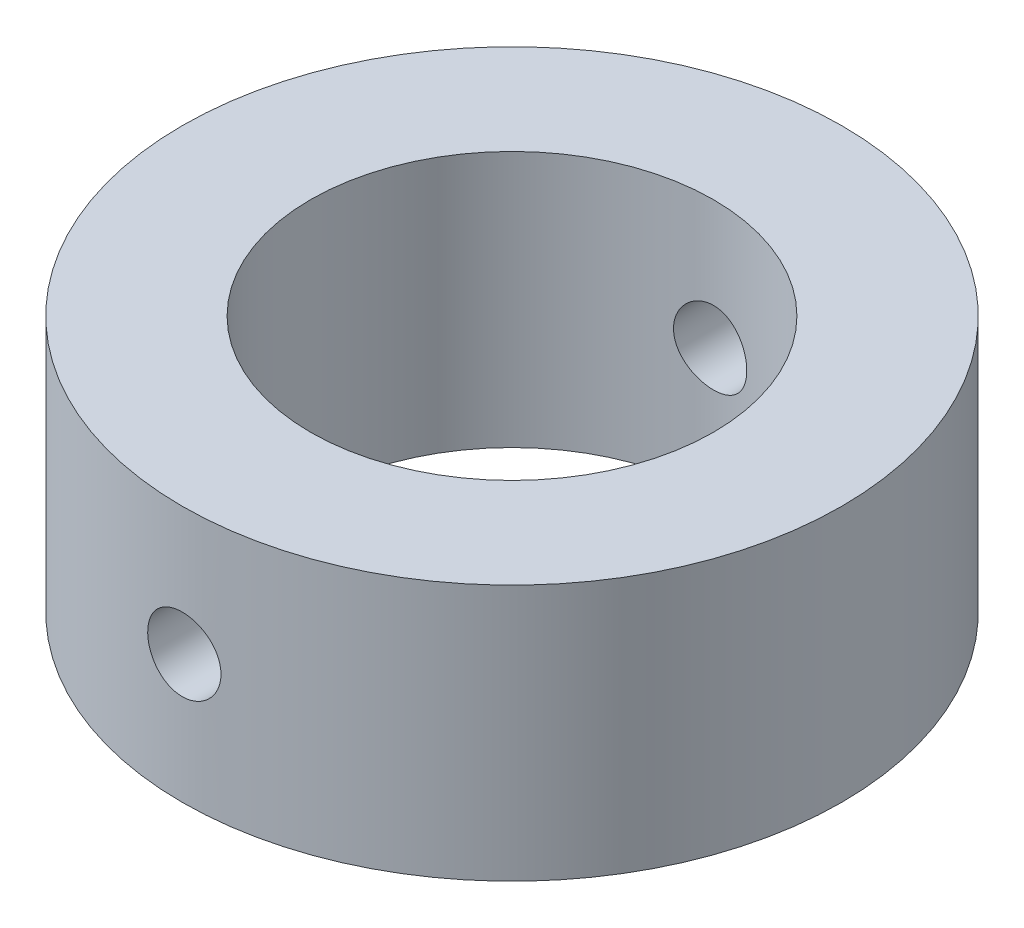
from build123d import *

# Parameters (mm, degrees)
SKETCH1_R               = 18
SKETCH1_R_2             = 11
BOSS_EXTRUDE1_DEPTH     = 7
SKETCH2_R               = 2
CUT_EXTRUDE1_DEPTH      = 19
CUT_EXTRUDE1_DEPTH_BACK = 19


with BuildPart() as part:
    # Sketch1 → Boss-Extrude1 (new body, symmetric)
    with BuildSketch(Plane(origin=(0, 0, 0), x_dir=(1, 0, 0), z_dir=(0, 1, 0))):
        Circle(SKETCH1_R)
        Circle(SKETCH1_R_2, mode=Mode.SUBTRACT)
    extrude(amount=BOSS_EXTRUDE1_DEPTH, both=True)

    # Sketch2 → Cut-Extrude1 (cut, two sides)
    with BuildSketch(Plane.XY) as cut_extrude1_sk:
        Circle(SKETCH2_R)
    extrude(amount=CUT_EXTRUDE1_DEPTH, mode=Mode.SUBTRACT)
    extrude(cut_extrude1_sk.sketch, amount=-CUT_EXTRUDE1_DEPTH_BACK, mode=Mode.SUBTRACT)


solid = part.part
